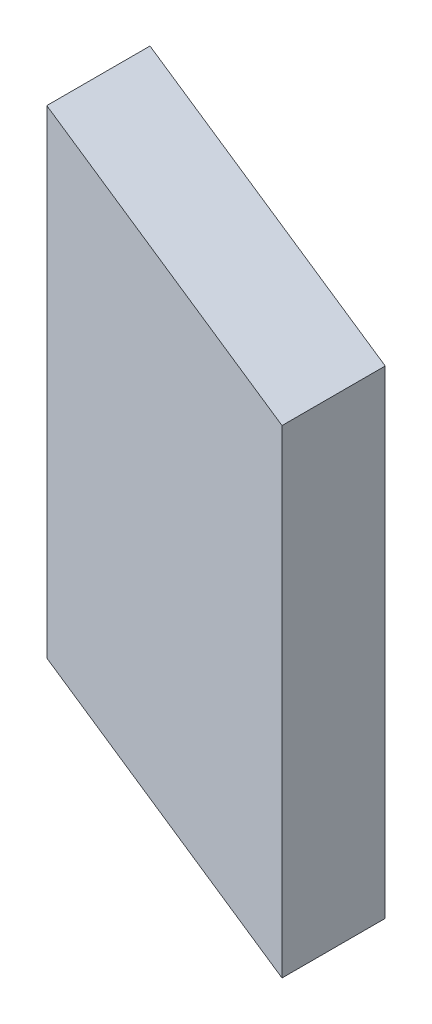
from build123d import *

# Parameters (mm, degrees)
BOSS_EXTRUDE1_DEPTH = 40


with BuildPart() as part:
    # Sketch1 → Boss-Extrude1 (new body)
    with BuildSketch(Plane(origin=(0, 0, 0), x_dir=(1, 0, 0), z_dir=(0, 1, 0))):
        Polygon((0, 26.371722059), (0, 35), (33, 21.667134547), (33, 13.038856606), align=None)
    extrude(amount=BOSS_EXTRUDE1_DEPTH)


solid = part.part
